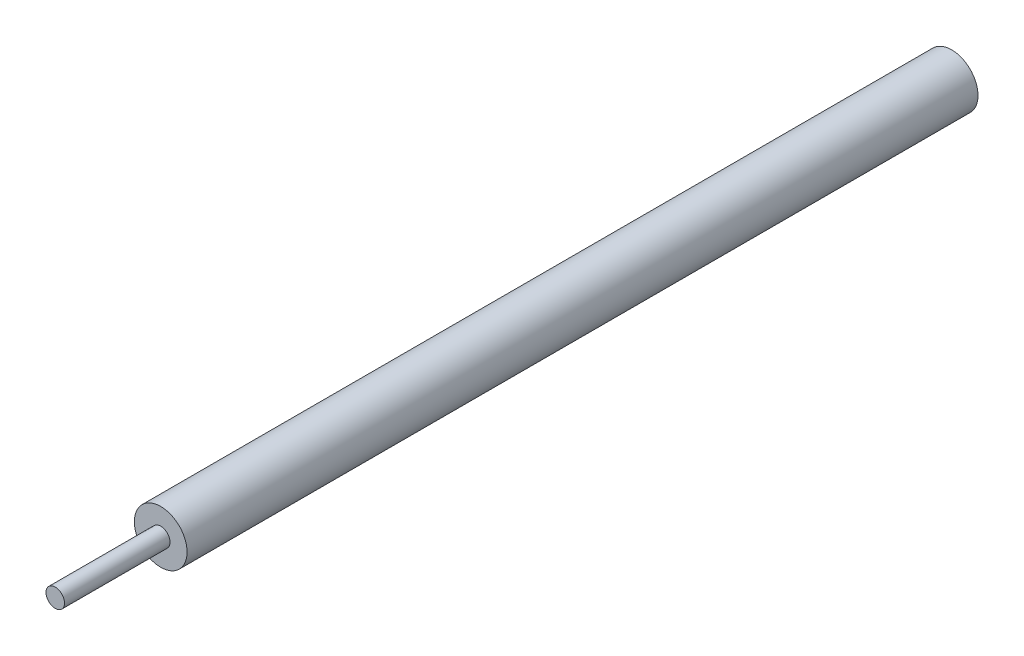
from build123d import *

# Parameters (mm, degrees)
SKETCH1_R           = 5
BOSS_EXTRUDE1_DEPTH = 150
SKETCH2_R           = 1.759192298
BOSS_EXTRUDE2_DEPTH = 20


with BuildPart() as part:
    # Sketch1 → Boss-Extrude1 (new body)
    with BuildSketch(Plane.XY):
        Circle(SKETCH1_R)
    extrude(amount=BOSS_EXTRUDE1_DEPTH)

    # Sketch2 → Boss-Extrude2 (add)
    with BuildSketch(Plane.XY.offset(150)):
        Circle(SKETCH2_R)
    extrude(amount=BOSS_EXTRUDE2_DEPTH)


solid = part.part
